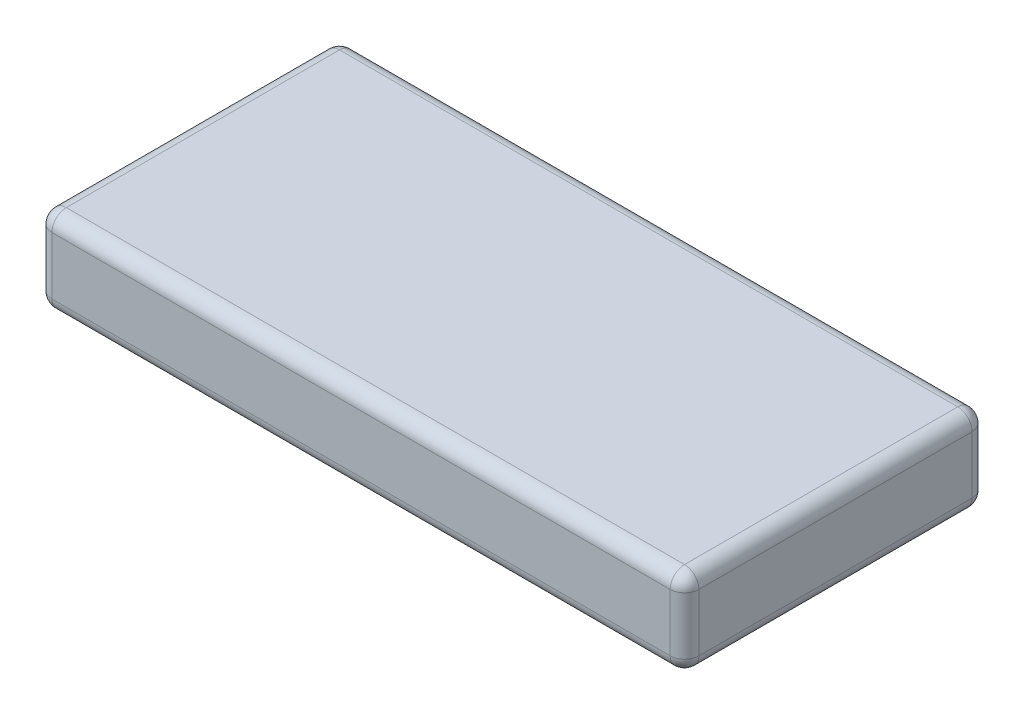
from build123d import *

# Parameters (mm, degrees)
SKETCH1_W           = 171.45
SKETCH1_H           = 80.01
BOSS_EXTRUDE1_DEPTH = 22.86
FILLET1_R           = 3.81


with BuildPart() as part:
    # Sketch1 → Boss-Extrude1 (new body)
    with BuildSketch(Plane(origin=(0, 0, 0), x_dir=(1, 0, 0), z_dir=(0, 1, 0))):
        with Locations((85.725, 40.005)):
            Rectangle(SKETCH1_W, SKETCH1_H)
    extrude(amount=BOSS_EXTRUDE1_DEPTH)

    # Fillet1
    fillet1_edges = [part.edges().sort_by_distance(p)[0] for p in [
        (171.45, 22.86, -40.005),
        (85.725, 22.86, -80.01),
        (0, 22.86, -40.005),
        (85.725, 0, -80.01),
        (171.45, 0, -40.005),
        (85.725, 0, 0),
        (0, 0, -40.005),
        (0, 11.43, -80.01),
        (171.45, 11.43, -80.01),
        (171.45, 11.43, 0),
        (0, 11.43, 0),
        (85.725, 22.86, 0),
    ]]
    fillet(fillet1_edges, radius=FILLET1_R)


solid = part.part
